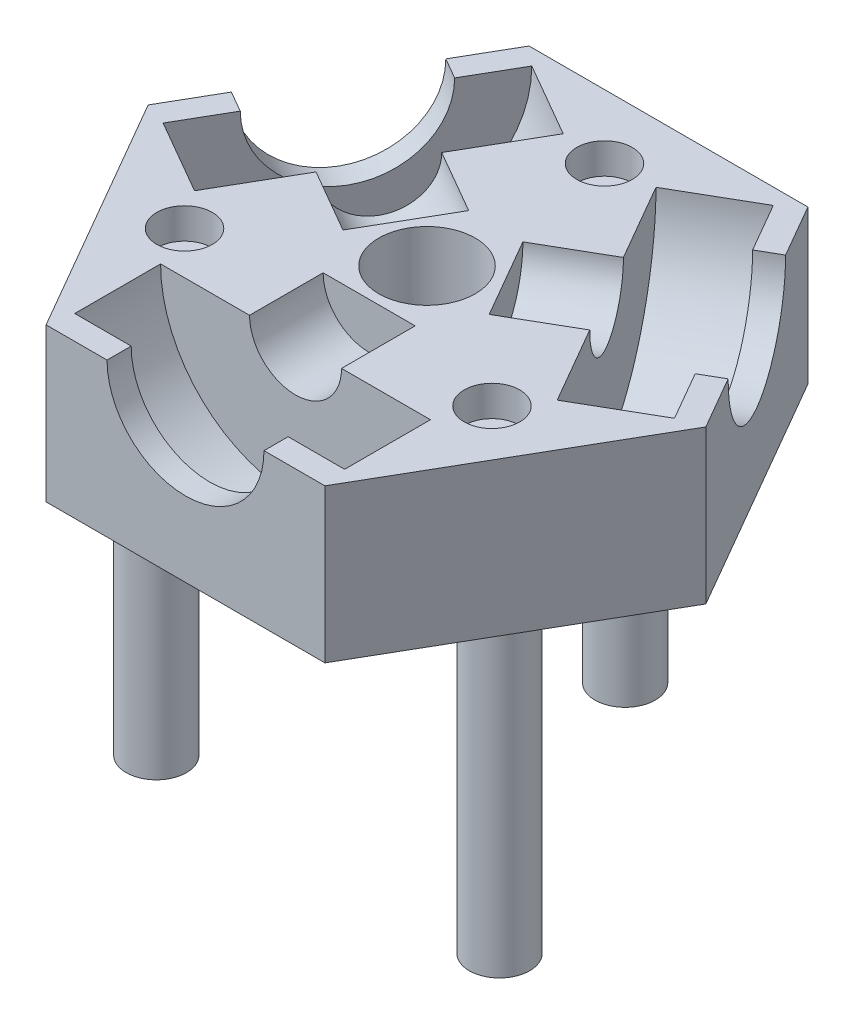
from build123d import *

# Parameters (mm, degrees)
BOSS_EXTRUDE1_DEPTH = 12.7
SKETCH2_R           = 5.5
SKETCH2_R_2         = 4.1
BOSS_EXTRUDE2_DEPTH = 3.499999906
CIRPATTERN1_COUNT   = 3
SKETCH6_R           = 4
CUT_EXTRUDE1_DEPTH  = 17.199999906
RANDOM_CIRCLES_R    = 2.3
CUT_EXTRUDE2_DEPTH  = 2.54
SKETCH8_R           = 2.5
BOSS_EXTRUDE3_DEPTH = 25.4


with BuildPart() as part:
    # Sketch1 → Boss-Extrude1 (new body)
    with BuildSketch(Plane(origin=(0, 0, 0), x_dir=(1, 0, 0), z_dir=(0, 1, 0))):
        Polygon((11.547005384, -20), (23.094010768, 0), (11.547005384, 20), (-11.547005384, 20), (-23.094010768, 0), (-11.547005384, -20), align=None)
    extrude(amount=BOSS_EXTRUDE1_DEPTH)

    # Sketch2 → Boss-Extrude2 (add)
    with BuildSketch(Plane.XZ):
        Circle(SKETCH2_R)
        Circle(SKETCH2_R_2, mode=Mode.SUBTRACT)
    extrude(amount=BOSS_EXTRUDE2_DEPTH)

    # Sketch5 → Cut-Revolve1 (revolve, cut)
    with BuildSketch(Plane(origin=(0, 12.7, 0), x_dir=(1, 0, 0), z_dir=(0, 1, 0))):
        Polygon((0, -20), (0, -4.792), (-3.81, -4.792), (-3.81, -10.888), (-11.176, -10.888), (-11.176, -18), (-6.5, -18), (-6.5, -20), align=None)
    cut_revolve1 = revolve(axis=Axis((0, 12.7, 20), (0, 0, -1)), mode=Mode.SUBTRACT)

    # CirPattern1: Cut-Revolve1 ×3 about axis
    cirpattern1_axis = Axis((0, 0, 0), (0, 1, 0))
    for i in range(1, CIRPATTERN1_COUNT):
        add(cut_revolve1.rotate(cirpattern1_axis, i * 360 / CIRPATTERN1_COUNT), mode=Mode.SUBTRACT)

    # Sketch6 → Cut-Extrude1 (cut, through all)
    with BuildSketch(Plane(origin=(0, 12.7, 0), x_dir=(1, 0, 0), z_dir=(0, 1, 0))):
        Circle(SKETCH6_R)
    extrude(amount=-CUT_EXTRUDE1_DEPTH, mode=Mode.SUBTRACT)

    # Random Circles → Cut-Extrude2 (cut)
    with BuildSketch(Plane(origin=(0, 12.7, 0), x_dir=(1, 0, 0), z_dir=(0, 1, 0))):
        with Locations((0, 14.7)):
            Circle(RANDOM_CIRCLES_R)
        with Locations((12.730569972, -7.350006)):
            Circle(RANDOM_CIRCLES_R)
        with Locations((-12.730580364, -7.35)):
            Circle(RANDOM_CIRCLES_R)
    extrude(amount=-CUT_EXTRUDE2_DEPTH, mode=Mode.SUBTRACT)

    # Sketch8 → Boss-Extrude3 (add)
    with BuildSketch(Plane(origin=(0, 0, 0), x_dir=(1, 0, 0), z_dir=(0, 1, 0))):
        with Locations((0, 16.40962)):
            Circle(SKETCH8_R)
        with Locations((14.211147786, -8.20481)):
            Circle(SKETCH8_R)
        with Locations((-14.211147786, -8.20481)):
            Circle(SKETCH8_R)
    extrude(amount=-BOSS_EXTRUDE3_DEPTH)


solid = part.part
